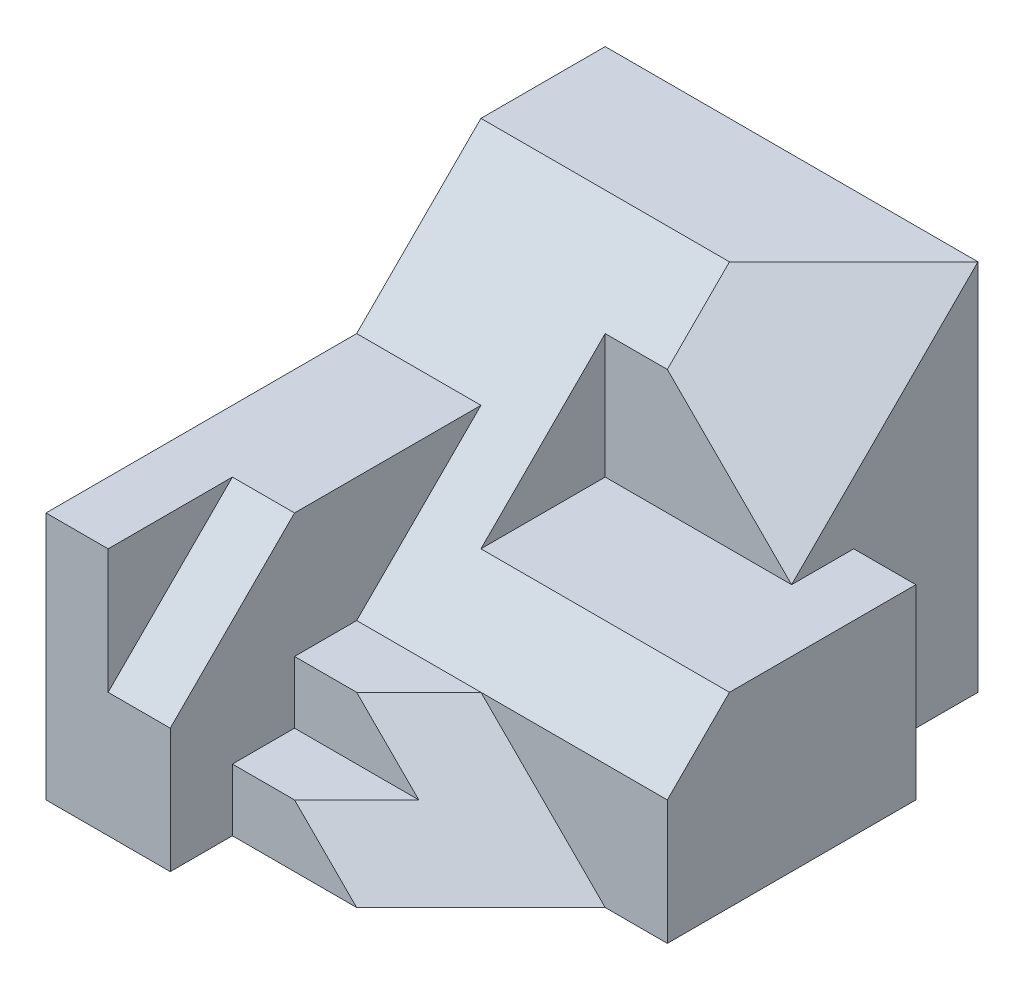
from build123d import *

# Parameters (mm, degrees)
SKETCH1_W           = 7
SKETCH1_H           = 6
BOSS_EXTRUDE1_DEPTH = 9
CUT_EXTRUDE1_DEPTH  = 2
CUT_EXTRUDE2_DEPTH  = 1
CUT_EXTRUDE3_DEPTH  = 6
SKETCH8_W           = 1
SKETCH8_H           = 4
CUT_EXTRUDE6_DEPTH  = 2
CUT_EXTRUDE7_DEPTH  = 1
SKETCH11_W          = 2
SKETCH11_H          = 1
CUT_EXTRUDE9_DEPTH  = 3
CUT_EXTRUDE11_DEPTH = 3
CUT_EXTRUDE12_DEPTH = 1
CUT_EXTRUDE13_DEPTH = 6
CUT_EXTRUDE14_DEPTH = 5
CUT_EXTRUDE16_DEPTH = 5
CUT_EXTRUDE17_DEPTH = 6.773502692
BOSS_EXTRUDE2_DEPTH = 4
CUT_EXTRUDE19_DEPTH = 4
CUT_EXTRUDE20_DEPTH = 3
CUT_EXTRUDE22_DEPTH = 6.773502692
CUT_EXTRUDE23_DEPTH = 10


with BuildPart() as part:
    # Sketch1 → Boss-Extrude1 (new body)
    with BuildSketch(Plane.XY):
        Rectangle(SKETCH1_W, SKETCH1_H)
    extrude(amount=BOSS_EXTRUDE1_DEPTH)

    # Sketch2 → Cut-Extrude1 (cut)
    with BuildSketch(Plane.ZY.offset(3.5)):
        Polygon((2, 3), (4, 1), (9, 1), (9, 3), align=None)
    extrude(amount=-CUT_EXTRUDE1_DEPTH, mode=Mode.SUBTRACT)

    # Sketch3 → Cut-Extrude2 (cut)
    with BuildSketch(Plane(origin=(3.5, 0, 0), x_dir=(0, 0, -1), z_dir=(1, 0, 0))):
        Polygon((0, -3), (-2, -3), (-2, 0), (-3, 0), (0, 3), align=None)
    extrude(amount=-CUT_EXTRUDE2_DEPTH, mode=Mode.SUBTRACT)

    # Sketch5 → Cut-Extrude3 (cut, through all)
    with BuildSketch(Plane.ZY.offset(1.5)):
        Polygon((2, 3), (4, 1), (9, 1), (9, 3), align=None)
    extrude(amount=-CUT_EXTRUDE3_DEPTH, mode=Mode.SUBTRACT)

    # Sketch8 → Cut-Extrude6 (cut)
    with BuildSketch(Plane(origin=(0, 3, 0), x_dir=(1, 0, 0), z_dir=(0, 1, 0))):
        with Locations((3, -2)):
            Rectangle(SKETCH8_W, SKETCH8_H)
    extrude(amount=-CUT_EXTRUDE6_DEPTH, mode=Mode.SUBTRACT)

    # Sketch9 → Cut-Extrude7 (cut)
    with BuildSketch(Plane(origin=(3.5, 0, 0), x_dir=(0, 0, -1), z_dir=(1, 0, 0))):
        Polygon((-2, 1), (-3, 0), (-5, 0), (-5, 1), align=None)
    extrude(amount=-CUT_EXTRUDE7_DEPTH, mode=Mode.SUBTRACT)

    # Sketch11 → Cut-Extrude9 (cut)
    with BuildSketch(Plane(origin=(3.5, 0, 0), x_dir=(0, 0, -1), z_dir=(1, 0, 0))):
        with Locations((-5, 0.5)):
            Rectangle(SKETCH11_W, SKETCH11_H)
    extrude(amount=-CUT_EXTRUDE9_DEPTH, mode=Mode.SUBTRACT)

    # Sketch13 → Cut-Extrude11 (cut)
    with BuildSketch(Plane(origin=(2.5, 0, 0), x_dir=(0, 0, -1), z_dir=(1, 0, 0))):
        Polygon((-5, 0), (-3, 0), (-3, 2), align=None)
    extrude(amount=-CUT_EXTRUDE11_DEPTH, mode=Mode.SUBTRACT)

    # Sketch14 → Cut-Extrude12 (cut)
    with BuildSketch(Plane(origin=(0.5, 0, 0), x_dir=(0, 0, -1), z_dir=(1, 0, 0))):
        Polygon((-4, 1), (-5, 0), (-6, 0), (-6, 1), align=None)
    extrude(amount=-CUT_EXTRUDE12_DEPTH, mode=Mode.SUBTRACT)

    # Sketch15 → Cut-Extrude13 (cut)
    with BuildSketch(Plane(origin=(3.5, 0, 0), x_dir=(0, 0, -1), z_dir=(1, 0, 0))):
        Polygon((-7, 1), (-9, -1), (-9, 1), align=None)
    extrude(amount=-CUT_EXTRUDE13_DEPTH, mode=Mode.SUBTRACT)

    # Sketch17 → Cut-Extrude14 (cut)
    with BuildSketch(Plane(origin=(3.5, 0, 0), x_dir=(0, 0, -1), z_dir=(1, 0, 0))):
        Polygon((-5, 0), (-6, 0), (-6, 1), (-7, 1), (-9, -1), (-9, -3), (-6, -3), (-6, -1), align=None)
    extrude(amount=-CUT_EXTRUDE14_DEPTH, mode=Mode.SUBTRACT)

    # Sketch18 → Cut-Extrude16 (cut)
    with BuildSketch(Plane(origin=(3.5, 0, 0), x_dir=(0, 0, -1), z_dir=(1, 0, 0))):
        Polygon((-3, 2), (-5, 0), (-6, 0), (-6, 1), align=None)
    extrude(amount=-CUT_EXTRUDE16_DEPTH, mode=Mode.SUBTRACT)

    # Sketch20 → Cut-Extrude17 (cut, through all)
    with BuildSketch(Plane(origin=(1.833333333, 1.833333333, 1.833333333), x_dir=(0.816496581, -0.40824829, -0.40824829), z_dir=(0.577350269, 0.577350269, 0.577350269))):
        Polygon((-1.632993162, 0.707106781), (-1.632993162, -0.707106781), (0.816496581, -2.121320344), (0.816496581, 2.121320344), align=None)
    extrude(amount=CUT_EXTRUDE17_DEPTH, mode=Mode.SUBTRACT)

    # Sketch21 → Boss-Extrude2 (add)
    with BuildSketch(Plane(origin=(-1.5, 0, 0), x_dir=(0, 0, -1), z_dir=(1, 0, 0))):
        Polygon((-6, -1), (-7, -1), (-7, -2), (-8, -2), (-8, -3), (-6, -3), align=None)
    extrude(amount=BOSS_EXTRUDE2_DEPTH)

    # Sketch24 → Cut-Extrude19 (cut)
    with BuildSketch(Plane(origin=(1.833333333, 1.833333333, 1.833333333), x_dir=(0.816496581, -0.40824829, -0.40824829), z_dir=(0.577350269, 0.577350269, 0.577350269))):
        Polygon((0.816496581, -6.363961031), (-1.632993162, -4.949747468), (-2.857738033, -5.656854249), (-1.632993162, -7.778174593), align=None)
    extrude(amount=CUT_EXTRUDE19_DEPTH, mode=Mode.SUBTRACT)

    # Sketch25 → Cut-Extrude20 (cut, through all)
    with BuildSketch(Plane(origin=(0, -1, 0), x_dir=(1, 0, 0), z_dir=(0, 1, 0))):
        Polygon((2.5, -6), (0.5, -8), (2.5, -8), align=None)
    extrude(amount=-CUT_EXTRUDE20_DEPTH, mode=Mode.SUBTRACT)

    # Sketch26 → Cut-Extrude22 (cut, through all)
    with BuildSketch(Plane(origin=(1.833333333, 1.833333333, 1.833333333), x_dir=(0.816496581, -0.40824829, -0.40824829), z_dir=(0.577350269, 0.577350269, 0.577350269))):
        Polygon((-1.632993162, -6.363961031), (-2.857738033, -7.071067812), (-1.632993162, -7.778174593), align=None)
    extrude(amount=CUT_EXTRUDE22_DEPTH, mode=Mode.SUBTRACT)

    # Sketch28 → Cut-Extrude23 (cut)
    with BuildSketch(Plane.XY.offset(6)):
        Polygon((0.5, -1), (2.5, -1), (2.5, -3), align=None)
    extrude(amount=CUT_EXTRUDE23_DEPTH, mode=Mode.SUBTRACT)


solid = part.part
